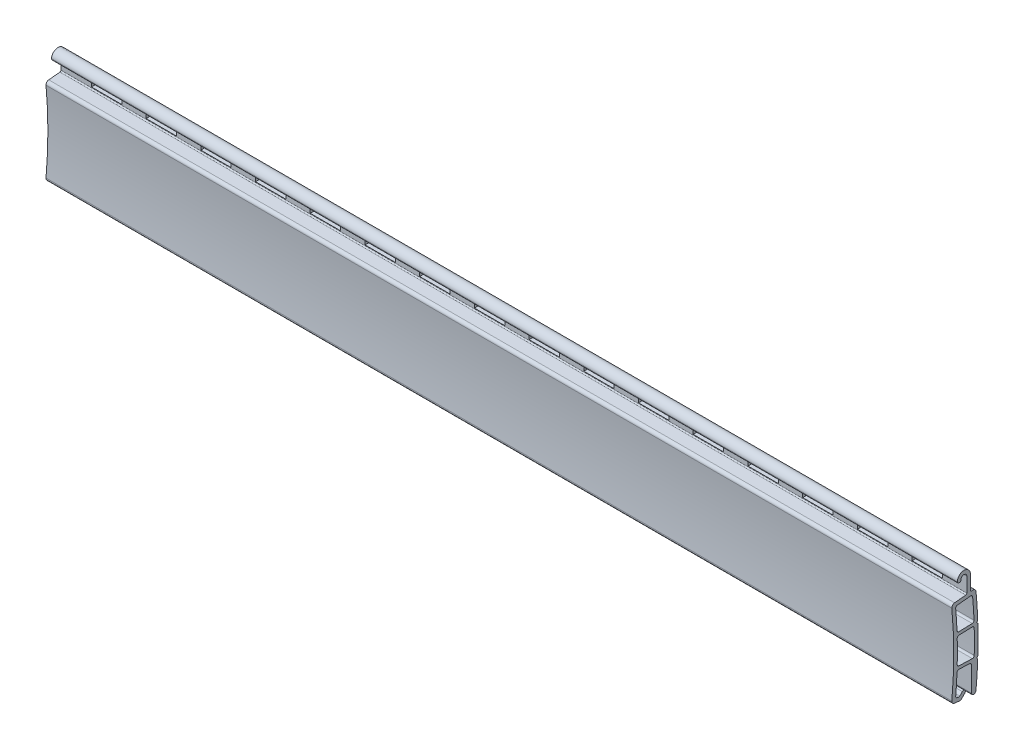
from build123d import *

# Parameters (mm, degrees)
BOSS_EXTRU_1_DEPTH      = 149
ESQUISSE2_W             = 5
ESQUISSE2_H             = 1
ENL_V_MAT_EXTRU_1_DEPTH = 10
BOSS_EXTRU_2_DEPTH      = 0.8


with BuildPart() as part:
    # Esquisse1 → Boss.-Extru.1 (new body)
    with BuildSketch(Plane(origin=(0, 0, 0), x_dir=(0, 0, -1), z_dir=(1, 0, 0))):
        with BuildLine():
            Line((-3.860137757, 7.149825173), (-2.026223342, 7.334140506))
            ThreePointArc((-2.026223342, 7.334140506), (-1.897899373, 7.398973915), (-1.846223342, 7.533137994))
            Line((-1.846223342, 7.533137994), (-1.846223342, 9.923189995))
            ThreePointArc((-1.846223342, 9.923189995), (-2.323033347, 10.4), (-2.799843352, 9.923189995))
            ThreePointArc((-2.799843352, 9.923189995), (-3.099843352, 9.623189995), (-3.399843352, 9.923189995))
            ThreePointArc((-3.399843352, 9.923189995), (-2.323033347, 11), (-1.246223342, 9.923189995))
            Line((-1.246223342, 9.923189995), (-1.246223342, 7.633641775))
            ThreePointArc((-1.246223342, 7.633641775), (-1.180387421, 7.485317806), (-1.026223342, 7.434644288))
            Line((-1.026223342, 7.434644288), (-0.875105396, 7.449832213))
            ThreePointArc((-0.875105396, 7.449832213), (-0.507382212, 7.338410998), (-0.327287312, 6.998998484))
            ThreePointArc((-0.327287312, 6.998998484), (-0.158294036, 4.870220563), (-0.049975817, 2.737494297))
            Line((-0.049975817, 2.737494297), (-0.242836784, 2.53111595))
            Line((-0.242836784, 2.53111595), (-0.036458437, 2.338254983))
            ThreePointArc((-0.036458437, 2.338254983), (0, 0), (-0.036458437, -2.338254983))
            Line((-0.036458437, -2.338254983), (-0.242836784, -2.53111595))
            Line((-0.242836784, -2.53111595), (-0.049975817, -2.737494297))
            ThreePointArc((-0.049975817, -2.737494297), (-0.162274501, -4.931008235), (-0.338755541, -7.12029324))
            ThreePointArc((-0.338755541, -7.12029324), (-0.734671234, -7.463418189), (-1.096223342, -7.084255902))
            Line((-1.096223342, -7.084255902), (-1.096223342, -3.042379931))
            ThreePointArc((-1.096223342, -3.042379931), (-1.180532058, -2.833867893), (-1.386071808, -2.742551736))
            Line((-1.386071808, -2.742551736), (-3.151738054, -2.682770094))
            ThreePointArc((-3.151738054, -2.682770094), (-3.365882071, -2.762627683), (-3.461631357, -2.970153511))
            ThreePointArc((-3.461631357, -2.970153511), (-3.549218264, -4.620150364), (-3.674856447, -6.267686745))
            ThreePointArc((-3.674856447, -6.267686745), (-3.607097173, -6.485253599), (-3.40600808, -6.592444233))
            Line((-3.40600808, -6.592444233), (-3.173338102, -6.615828446))
            ThreePointArc((-3.173338102, -6.615828446), (-3.086147781, -6.605206809), (-3.011916745, -6.558252315))
            Line((-3.011916745, -6.558252315), (-2.589662269, -6.135997838))
            ThreePointArc((-2.589662269, -6.135997838), (-2.1653982, -6.135997838), (-2.1653982, -6.560261907))
            Line((-2.1653982, -6.560261907), (-2.755302232, -7.150165939))
            ThreePointArc((-2.755302232, -7.150165939), (-2.866648786, -7.22059768), (-2.997434267, -7.236530136))
            Line((-2.997434267, -7.236530136), (-3.860137757, -7.149825173))
            ThreePointArc((-3.860137757, -7.149825173), (-4.19616552, -6.970108995), (-4.307968961, -6.605811654))
            ThreePointArc((-4.307968961, -6.605811654), (-4, 0), (-4.307968961, 6.605811654))
            ThreePointArc((-4.307968961, 6.605811654), (-4.19616552, 6.970108995), (-3.860137757, 7.149825173))
        make_face()
        with BuildLine():
            Line((-3.40600808, 6.592444233), (-1.216869301, 6.812460959))
            ThreePointArc((-1.216869301, 6.812460959), (-0.995606652, 6.745089367), (-0.888030716, 6.540337055))
            ThreePointArc((-0.888030716, 6.540337055), (-0.755400782, 4.806192566), (-0.663342485, 3.069421689))
            ThreePointArc((-0.663342485, 3.069421689), (-0.743139633, 2.853027528), (-0.952935537, 2.757216794))
            Line((-0.952935537, 2.757216794), (-3.151738054, 2.682770094))
            ThreePointArc((-3.151738054, 2.682770094), (-3.365882071, 2.762627683), (-3.461631357, 2.970153511))
            ThreePointArc((-3.461631357, 2.970153511), (-3.549218264, 4.620150364), (-3.674856447, 6.267686745))
            ThreePointArc((-3.674856447, 6.267686745), (-3.607097173, 6.485253599), (-3.40600808, 6.592444233))
        make_face(mode=Mode.SUBTRACT)
        with BuildLine():
            Line((-3.13481883, 2.183056436), (-0.936016313, 2.257503136))
            ThreePointArc((-0.936016313, 2.257503136), (-0.720220399, 2.176102021), (-0.625969494, 1.965600751))
            ThreePointArc((-0.625969494, 1.965600751), (-0.6, 0), (-0.625969494, -1.965600751))
            ThreePointArc((-0.625969494, -1.965600751), (-0.720220399, -2.176102021), (-0.936016313, -2.257503136))
            Line((-0.936016313, -2.257503136), (-3.13481883, -2.183056436))
            ThreePointArc((-3.13481883, -2.183056436), (-3.343071021, -2.088897423), (-3.424564372, -1.875370543))
            ThreePointArc((-3.424564372, -1.875370543), (-3.4, 0), (-3.424564372, 1.875370543))
            ThreePointArc((-3.424564372, 1.875370543), (-3.343071021, 2.088897423), (-3.13481883, 2.183056436))
        make_face(mode=Mode.SUBTRACT)
    extrude(amount=BOSS_EXTRU_1_DEPTH)

    # Esquisse2 → Enlèv. mat.-Extru.1 (cut)
    with BuildSketch(Plane(origin=(0, 0, 1.246223342), x_dir=(-1, 0, 0), z_dir=(0, 0, -1))):
        with Locations((-16.5, 8.133641775)):
            Rectangle(ESQUISSE2_W, ESQUISSE2_H)
        with Locations((-25.5, 8.133641775)):
            Rectangle(ESQUISSE2_W, ESQUISSE2_H)
        with Locations((-34.5, 8.133641775)):
            Rectangle(ESQUISSE2_W, ESQUISSE2_H)
        with Locations((-43.5, 8.133641775)):
            Rectangle(ESQUISSE2_W, ESQUISSE2_H)
        with Locations((-52.5, 8.133641775)):
            Rectangle(ESQUISSE2_W, ESQUISSE2_H)
        with Locations((-61.5, 8.133641775)):
            Rectangle(ESQUISSE2_W, ESQUISSE2_H)
        with Locations((-70.5, 8.133641775)):
            Rectangle(ESQUISSE2_W, ESQUISSE2_H)
        with Locations((-79.5, 8.133641775)):
            Rectangle(ESQUISSE2_W, ESQUISSE2_H)
        with Locations((-88.5, 8.133641775)):
            Rectangle(ESQUISSE2_W, ESQUISSE2_H)
        with Locations((-97.5, 8.133641775)):
            Rectangle(ESQUISSE2_W, ESQUISSE2_H)
        with Locations((-106.5, 8.133641775)):
            Rectangle(ESQUISSE2_W, ESQUISSE2_H)
        with Locations((-115.5, 8.133641775)):
            Rectangle(ESQUISSE2_W, ESQUISSE2_H)
        with Locations((-124.5, 8.133641775)):
            Rectangle(ESQUISSE2_W, ESQUISSE2_H)
        with Locations((-133.5, 8.133641775)):
            Rectangle(ESQUISSE2_W, ESQUISSE2_H)
        with Locations((-142.5, 8.133641775)):
            Rectangle(ESQUISSE2_W, ESQUISSE2_H)
        with Locations((-7.5, 8.133641775)):
            Rectangle(ESQUISSE2_W, ESQUISSE2_H)
    extrude(amount=-ENL_V_MAT_EXTRU_1_DEPTH, mode=Mode.SUBTRACT)

    # Esquisse3 → Boss.-Extru.2 (add)
    with BuildSketch(Plane(origin=(3, 0, 0), x_dir=(0, 0, -1), z_dir=(1, 0, 0))):
        Polygon((-0.731399953, 7.027076964), (-3.950090787, 6.781472062), (-3.644671914, 2.430217171), (-3.644671914, -2.406699487), (-0.369395227, -2.522851648), (-0.391249224, 2.569348219), align=None)
    boss_extru_2 = extrude(amount=BOSS_EXTRU_2_DEPTH)

    # Symétrie1: Boss.-Extru.2 across plane
    add(boss_extru_2.mirror(Plane(origin=(74.5, 0, 0), x_dir=(0, 0, 1), z_dir=(1, 0, 0))))


solid = part.part
